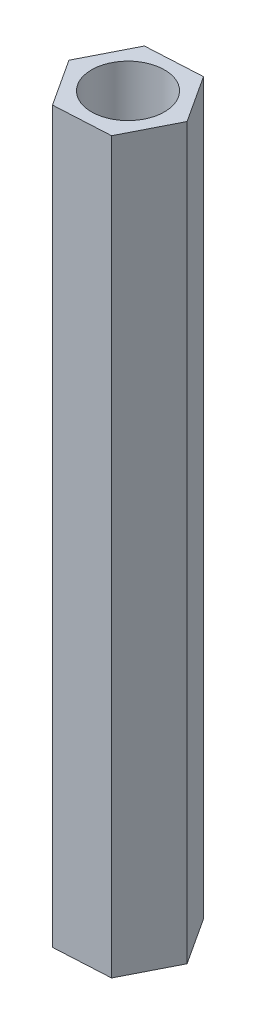
from build123d import *

# Parameters (mm, degrees)
SKETCH1_R           = 1.5
BOSS_EXTRUDE1_DEPTH = 30


with BuildPart() as part:
    # Sketch1 → Boss-Extrude1 (new body)
    with BuildSketch(Plane(origin=(0, 0, 0), x_dir=(1, 0, 0), z_dir=(0, 1, 0))):
        Polygon((-1.26017821, 1.935273679), (-2.306085274, -0.123709503), (-1.045907065, -2.058983182), (1.26017821, -1.935273679), (2.306085274, 0.123709503), (1.045907065, 2.058983182), align=None)
        Circle(SKETCH1_R, mode=Mode.SUBTRACT)
    extrude(amount=BOSS_EXTRUDE1_DEPTH)


solid = part.part
